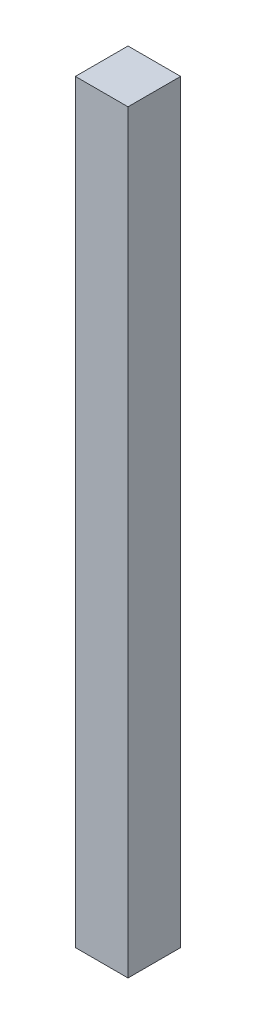
from build123d import *

# Parameters (mm, degrees)
SKETCH1_W           = 6
SKETCH1_H           = 6
BOSS_EXTRUDE1_DEPTH = 86


with BuildPart() as part:
    # Sketch1 → Boss-Extrude1 (new body)
    with BuildSketch(Plane(origin=(0, 0, 0), x_dir=(1, 0, 0), z_dir=(0, 1, 0))):
        with Locations((3, -3)):
            Rectangle(SKETCH1_W, SKETCH1_H)
    extrude(amount=BOSS_EXTRUDE1_DEPTH)


solid = part.part
